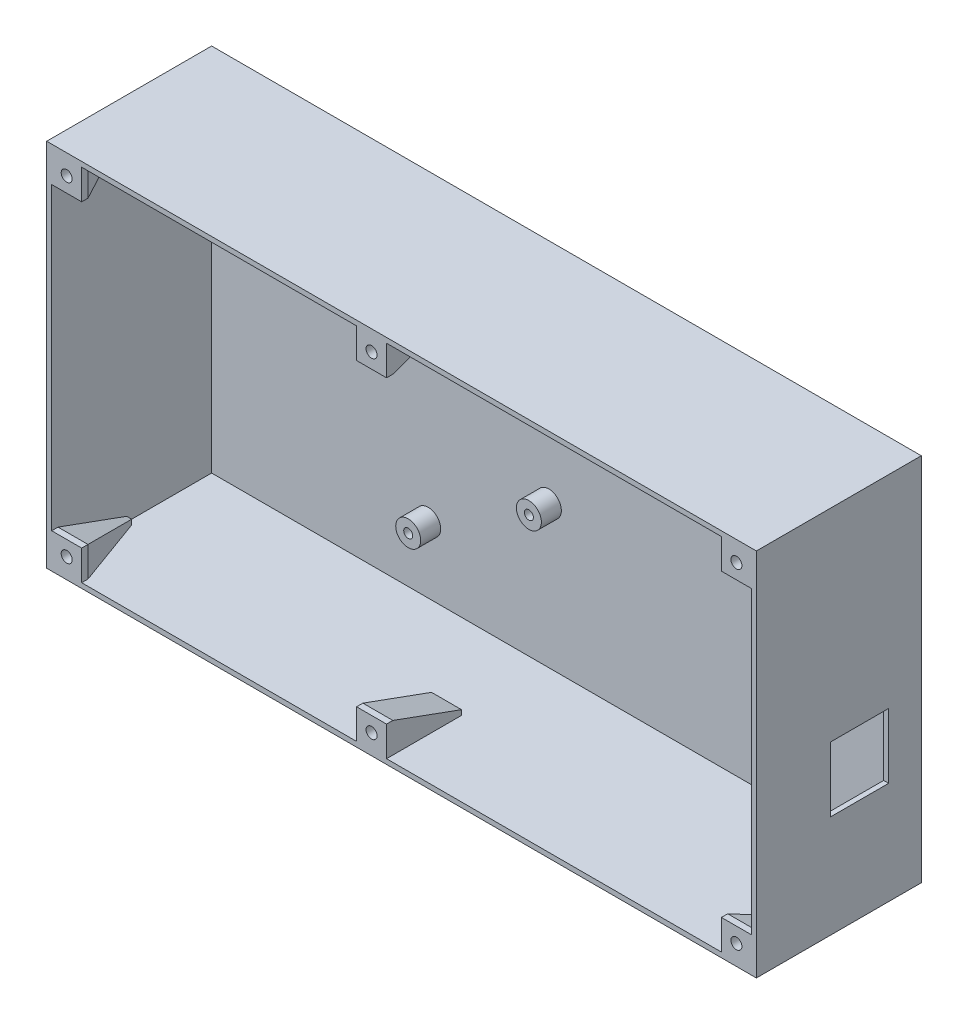
from build123d import *

# Parameters (mm, degrees)
ESQUISSE1_W             = 142
ESQUISSE1_H             = 74
BOSS_EXTRU_1_DEPTH      = 1
ESQUISSE2_W             = 142
ESQUISSE2_H             = 74
ESQUISSE2_W_2           = 140
ESQUISSE2_H_2           = 72
BOSS_EXTRU_2_DEPTH      = 32
ESQUISSE3_W             = 6
ESQUISSE3_H             = 6
BOSS_EXTRU_3_DEPTH      = 15
CHANFREIN1_SIZE         = 5
CHANFREIN1_SIZE2        = 13.737387097
CHANFREIN1_PART_2_SIZE  = 5
CHANFREIN1_PART_2_SIZE2 = 13.737387097
CHANFREIN1_PART_3_SIZE  = 5
CHANFREIN1_PART_3_SIZE2 = 13.737387097
CHANFREIN1_PART_4_SIZE  = 5
CHANFREIN1_PART_4_SIZE2 = 13.737387097
CHANFREIN1_PART_5_SIZE  = 5
CHANFREIN1_PART_5_SIZE2 = 13.737387097
CHANFREIN1_PART_6_SIZE  = 5
CHANFREIN1_PART_6_SIZE2 = 13.737387097
ESQUISSE4_R             = 1.1
ENL_V_MAT_EXTRU_1_DEPTH = 4
ESQUISSE5_R             = 2.5
ESQUISSE5_R_2           = 0.9
BOSS_EXTRU_4_DEPTH      = 4
ESQUISSE6_W             = 11.635872756
ESQUISSE6_H             = 12.977079273
ENL_V_MAT_EXTRU_2_DEPTH = 3


with BuildPart() as part:
    # Esquisse1 → Boss.-Extru.1 (new body)
    with BuildSketch(Plane.XY):
        with Locations((71, 37)):
            Rectangle(ESQUISSE1_W, ESQUISSE1_H)
    extrude(amount=BOSS_EXTRU_1_DEPTH)

    # Esquisse2 → Boss.-Extru.2 (add)
    with BuildSketch(Plane.XY.offset(1)):
        with Locations((71, 37)):
            Rectangle(ESQUISSE2_W, ESQUISSE2_H)
        with Locations((71, 37)):
            Rectangle(ESQUISSE2_W_2, ESQUISSE2_H_2, mode=Mode.SUBTRACT)
    extrude(amount=BOSS_EXTRU_2_DEPTH)

    # Esquisse3 → Boss.-Extru.3 (add)
    with BuildSketch(Plane.XY.offset(33)):
        with Locations((4, 70)):
            Rectangle(ESQUISSE3_W, ESQUISSE3_H)
        with Locations((138, 70)):
            Rectangle(ESQUISSE3_W, ESQUISSE3_H)
        with Locations((138, 4)):
            Rectangle(ESQUISSE3_W, ESQUISSE3_H)
        with Locations((4, 4)):
            Rectangle(ESQUISSE3_W, ESQUISSE3_H)
        with Locations((65, 4)):
            Rectangle(ESQUISSE3_W, ESQUISSE3_H)
        with Locations((65, 70)):
            Rectangle(ESQUISSE3_W, ESQUISSE3_H)
    extrude(amount=-BOSS_EXTRU_3_DEPTH)

    # Chanfrein1
    chanfrein1_edges = [part.edges().sort_by_distance(p)[0] for p in [
        (7, 70, 18),
        (4, 67, 18),
    ]]
    chanfrein1_side = [part.faces().sort_by_distance(p)[0] for p in [
        (4, 70, 18),
    ]]
    chamfer(chanfrein1_edges, length=CHANFREIN1_SIZE, length2=CHANFREIN1_SIZE2, reference=chanfrein1_side[0])

    # Chanfrein1 part 2
    chanfrein1_part_2_edges = [part.edges().sort_by_distance(p)[0] for p in [
        (138, 67, 18),
        (135, 70, 18),
    ]]
    chanfrein1_part_2_side = [part.faces().sort_by_distance(p)[0] for p in [
        (138, 70, 18),
    ]]
    chamfer(chanfrein1_part_2_edges, length=CHANFREIN1_PART_2_SIZE, length2=CHANFREIN1_PART_2_SIZE2, reference=chanfrein1_part_2_side[0])

    # Chanfrein1 part 3
    chanfrein1_part_3_edges = [part.edges().sort_by_distance(p)[0] for p in [
        (135, 4, 18),
        (138, 7, 18),
    ]]
    chanfrein1_part_3_side = [part.faces().sort_by_distance(p)[0] for p in [
        (138, 4, 18),
    ]]
    chamfer(chanfrein1_part_3_edges, length=CHANFREIN1_PART_3_SIZE, length2=CHANFREIN1_PART_3_SIZE2, reference=chanfrein1_part_3_side[0])

    # Chanfrein1 part 4
    chanfrein1_part_4_edges = [part.edges().sort_by_distance(p)[0] for p in [
        (4, 7, 18),
        (7, 4, 18),
    ]]
    chanfrein1_part_4_side = [part.faces().sort_by_distance(p)[0] for p in [
        (4, 4, 18),
    ]]
    chamfer(chanfrein1_part_4_edges, length=CHANFREIN1_PART_4_SIZE, length2=CHANFREIN1_PART_4_SIZE2, reference=chanfrein1_part_4_side[0])

    # Chanfrein1 part 5
    chanfrein1_part_5_edges = [part.edges().sort_by_distance(p)[0] for p in [
        (65, 7, 18),
    ]]
    chanfrein1_part_5_side = [part.faces().sort_by_distance(p)[0] for p in [
        (65, 4, 18),
    ]]
    chamfer(chanfrein1_part_5_edges, length=CHANFREIN1_PART_5_SIZE, length2=CHANFREIN1_PART_5_SIZE2, reference=chanfrein1_part_5_side[0])

    # Chanfrein1 part 6
    chanfrein1_part_6_edges = [part.edges().sort_by_distance(p)[0] for p in [
        (65, 67, 18),
    ]]
    chanfrein1_part_6_side = [part.faces().sort_by_distance(p)[0] for p in [
        (65, 70, 18),
    ]]
    chamfer(chanfrein1_part_6_edges, length=CHANFREIN1_PART_6_SIZE, length2=CHANFREIN1_PART_6_SIZE2, reference=chanfrein1_part_6_side[0])

    # Esquisse4 → Enlèv. mat.-Extru.1 (cut)
    with BuildSketch(Plane.XY.offset(33)):
        with Locations((4, 70)):
            Circle(ESQUISSE4_R)
        with Locations((65, 70)):
            Circle(ESQUISSE4_R)
        with Locations((138, 70)):
            Circle(ESQUISSE4_R)
        with Locations((138, 4)):
            Circle(ESQUISSE4_R)
        with Locations((65, 4)):
            Circle(ESQUISSE4_R)
        with Locations((4, 4)):
            Circle(ESQUISSE4_R)
    extrude(amount=-ENL_V_MAT_EXTRU_1_DEPTH, mode=Mode.SUBTRACT)

    # Esquisse5 → Boss.-Extru.4 (add)
    with BuildSketch(Plane.XY.offset(1)):
        with Locations((38, 62.5)):
            Circle(ESQUISSE5_R)
        with Locations((38, 62.5)):
            Circle(ESQUISSE5_R_2, mode=Mode.SUBTRACT)
        with Locations((68.48, 57.42)):
            Circle(ESQUISSE5_R)
        with Locations((68.48, 57.42)):
            Circle(ESQUISSE5_R_2, mode=Mode.SUBTRACT)
        with Locations((68.48, 29.48)):
            Circle(ESQUISSE5_R)
        with Locations((68.48, 29.48)):
            Circle(ESQUISSE5_R_2, mode=Mode.SUBTRACT)
        with Locations((44.336188826, 14.23343905)):
            Circle(ESQUISSE5_R)
        with Locations((44.336188826, 14.23343905)):
            Circle(ESQUISSE5_R_2, mode=Mode.SUBTRACT)
        with Locations((120.550955535, 62.5)):
            Circle(ESQUISSE5_R)
        with Locations((120.550955535, 62.5)):
            Circle(ESQUISSE5_R_2, mode=Mode.SUBTRACT)
        with Locations((119.28, 14.24)):
            Circle(ESQUISSE5_R)
        with Locations((119.28, 14.24)):
            Circle(ESQUISSE5_R_2, mode=Mode.SUBTRACT)
    extrude(amount=BOSS_EXTRU_4_DEPTH)

    # Esquisse6 → Enlèv. mat.-Extru.2 (cut)
    with BuildSketch(Plane(origin=(142, 0, 0), x_dir=(0, 0, -1), z_dir=(1, 0, 0))):
        with Locations((-12.35060992, 26.988539637)):
            Rectangle(ESQUISSE6_W, ESQUISSE6_H)
    extrude(amount=-ENL_V_MAT_EXTRU_2_DEPTH, mode=Mode.SUBTRACT)


solid = part.part
